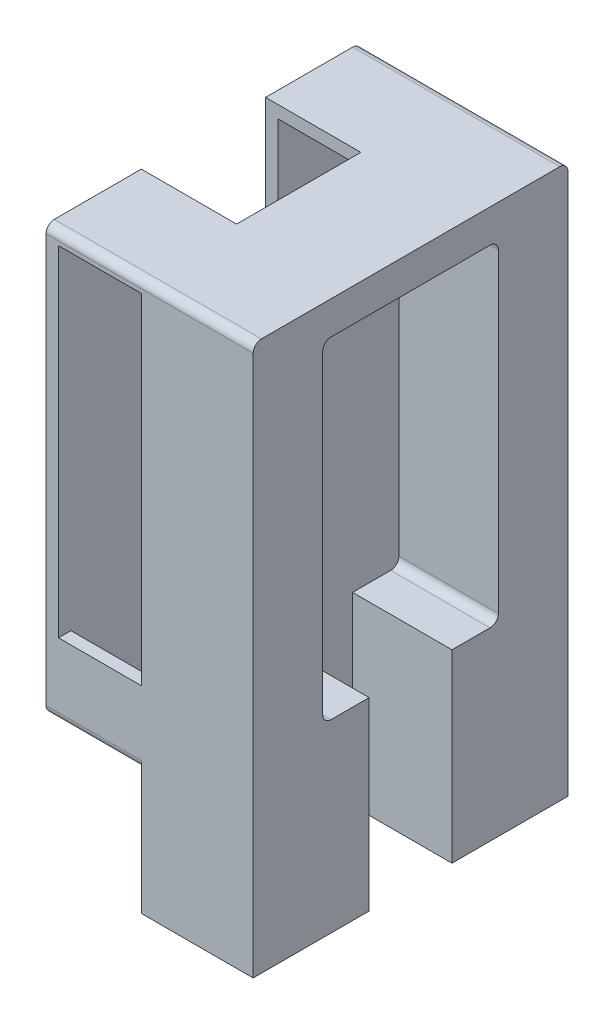
from build123d import *

# Parameters (mm, degrees)
SKETCH1_W                = 31.75
SKETCH1_H                = 84.214152012
BOSS_EXTRUDE1_DEPTH      = 1.905
BOSS_EXTRUDE1_DEPTH_BACK = 46.355
SKETCH3_W                = 12.7
SKETCH3_H                = 52.07
SKETCH3_W_2              = 14.605
SKETCH3_H_2              = 19.05
CUT_EXTRUDE1_DEPTH       = 49.26
CUT_EXTRUDE2_DEPTH       = 65.405
CUT_EXTRUDE3_DEPTH       = 14.605
CUT_EXTRUDE4_REACH       = 67.164
CUT_EXTRUDE5_DEPTH       = 15.24
SKETCH8_R                = 1.016
BOSS_EXTRUDE2_DEPTH      = 5.08
FILLET1_R                = 1.27
FILLET2_R                = 1.27


with BuildPart() as part:
    # Sketch1 → Boss-Extrude1 (new body, two sides)
    with BuildSketch(Plane.XY) as boss_extrude1_sk:
        with Locations((15.875, -42.107076006)):
            Rectangle(SKETCH1_W, SKETCH1_H)
    extrude(amount=BOSS_EXTRUDE1_DEPTH)
    extrude(boss_extrude1_sk.sketch, amount=-BOSS_EXTRUDE1_DEPTH_BACK)

    # Sketch3 → Cut-Extrude1 (cut, through all)
    with BuildSketch(Plane.XY.offset(1.905)):
        with Locations((8.255, -27.94)):
            Rectangle(SKETCH3_W, SKETCH3_H)
        with Locations((7.3025, -74.689152012)):
            Rectangle(SKETCH3_W_2, SKETCH3_H_2)
    extrude(amount=-CUT_EXTRUDE1_DEPTH, mode=Mode.SUBTRACT)

    # Sketch4 → Cut-Extrude2 (cut)
    with BuildSketch(Plane(origin=(0, 0, 0), x_dir=(1, 0, 0), z_dir=(0, 1, 0))):
        Polygon((1.905, 22.225), (1.905, 31.75), (14.405235248, 31.75), (14.405235248, 12.7), (1.905, 12.7), align=None)
    extrude(amount=-CUT_EXTRUDE2_DEPTH, mode=Mode.SUBTRACT)

    # Sketch5 → Cut-Extrude3 (cut)
    with BuildSketch(Plane.ZY):
        Polygon((-22.225, 0), (-12.7, 0), (-12.7, -52.705), (-31.75, -52.705), (-31.75, 0), align=None)
    extrude(amount=-CUT_EXTRUDE3_DEPTH, mode=Mode.SUBTRACT)

    # Sketch6 → Cut-Extrude4 (cut, up to next)
    with BuildSketch(Plane.XZ.offset(65.164152012), mode=Mode.PRIVATE) as cut_extrude4_sk1:
        Polygon((1.905, -22.225), (1.905, 0), (14.605, 0), (14.605, -44.45), (1.905, -44.45), align=None)
    cut_extrude4_tool1 = extrude(cut_extrude4_sk1.sketch, amount=-CUT_EXTRUDE4_REACH, mode=Mode.PRIVATE) & part.part
    add(cut_extrude4_tool1.solids().sort_by_distance((8.255, -65.164152, -22.225))[0], mode=Mode.SUBTRACT)

    # Sketch7 → Cut-Extrude5 (cut)
    with BuildSketch(Plane(origin=(31.75, 0, 0), x_dir=(0, 0, -1), z_dir=(1, 0, 0))):
        Polygon((22.225, -5.08), (35.687, -5.08), (35.687, -55.88), (28.575, -55.88), (28.575, -84.214152012), (15.875, -84.214152012), (15.875, -55.88), (8.763, -55.88), (8.763, -5.08), align=None)
    extrude(amount=-CUT_EXTRUDE5_DEPTH, mode=Mode.SUBTRACT)

    # Sketch8 → Boss-Extrude2 (add)
    with BuildSketch(Plane(origin=(16.51, 0, 0), x_dir=(0, 0, -1), z_dir=(1, 0, 0))):
        with Locations((33.655, -7.62)):
            Circle(SKETCH8_R)
        with Locations((10.795, -7.62)):
            Circle(SKETCH8_R)
    extrude(amount=BOSS_EXTRUDE2_DEPTH)

    # Fillet1
    fillet1_edges = [part.edges().sort_by_distance(p)[0] for p in [
        (24.13, -5.08, -8.763),
        (24.13, -5.08, -35.687),
        (24.13, -55.88, -35.687),
        (24.13, -55.88, -8.763),
    ]]
    fillet(fillet1_edges, radius=FILLET1_R)

    # Fillet2
    fillet2_edges = [part.edges().sort_by_distance(p)[0] for p in [
        (15.875, 0, -46.355),
        (15.875, 0, 1.905),
        (7.3025, -65.164152012, -46.355),
        (7.3025, -65.164152012, 1.905),
    ]]
    fillet(fillet2_edges, radius=FILLET2_R)


solid = part.part
